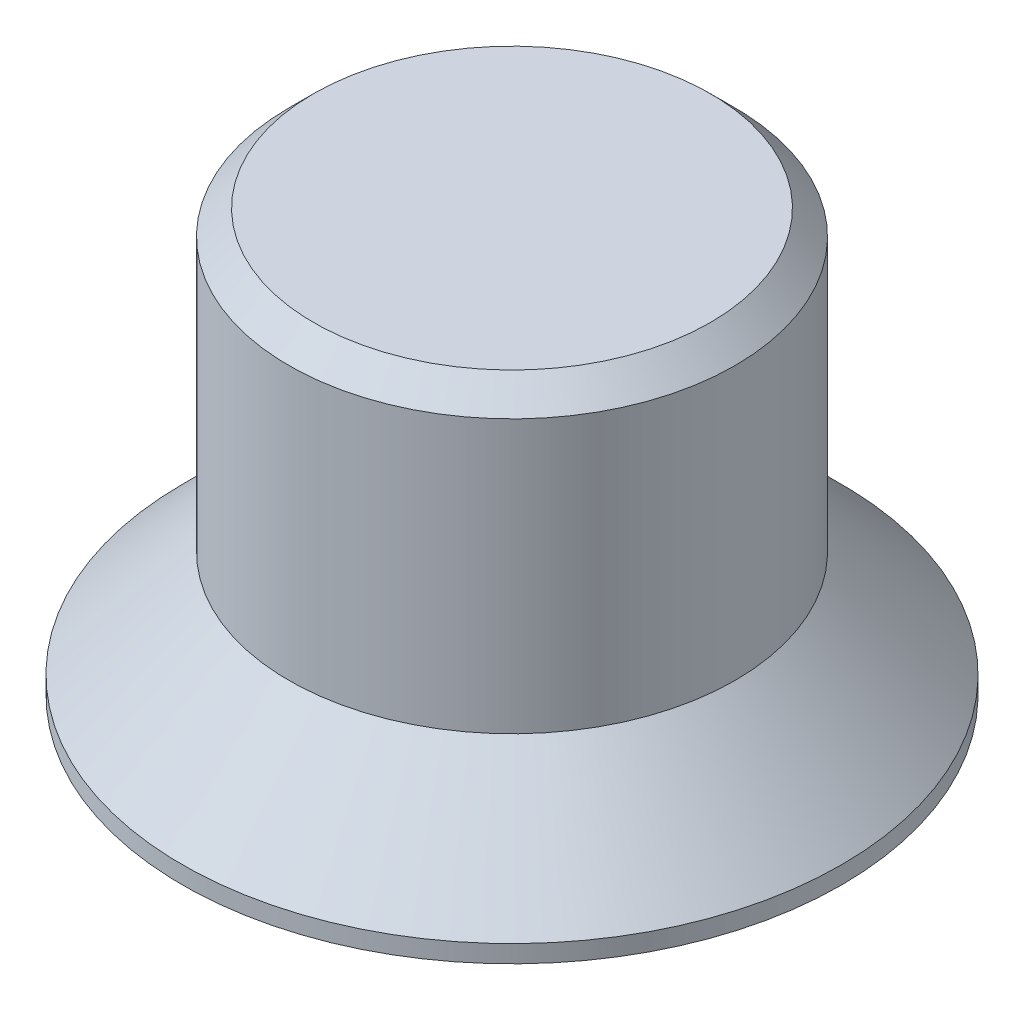
from build123d import *

# Parameters (mm, degrees)
CHAMFER1_SIZE  = 0.25
CHAMFER2_SIZE  = 0.25
CHAMFER2_SIZE2 = 0.176776695


with BuildPart() as part:
    # Sketch1 → Revolve1 (revolve)
    with BuildSketch(Plane.XY):
        Polygon((0, 0.25), (1.5, 0.25), (1.544081745, 0), (3.5, 0), (2.25, 1.25), (2.25, 4.25), (0, 4.25), align=None)
    revolve(axis=Axis((0, -277.798061763, 0), (0, 1, 0)))

    # Chamfer1
    chamfer1_edges = [part.edges().sort_by_distance(p)[0] for p in [
        (-2.25, 4.25, 0),
    ]]
    chamfer(chamfer1_edges, length=CHAMFER1_SIZE)

    # Chamfer2
    chamfer2_edges = [part.edges().sort_by_distance(p)[0] for p in [
        (-3.5, 0, 0),
    ]]
    chamfer2_side = [part.faces().sort_by_distance(p)[0] for p in [
        (-2.875, 0.625, 0),
    ]]
    chamfer(chamfer2_edges, length=CHAMFER2_SIZE, length2=CHAMFER2_SIZE2, reference=chamfer2_side[0])


solid = part.part
